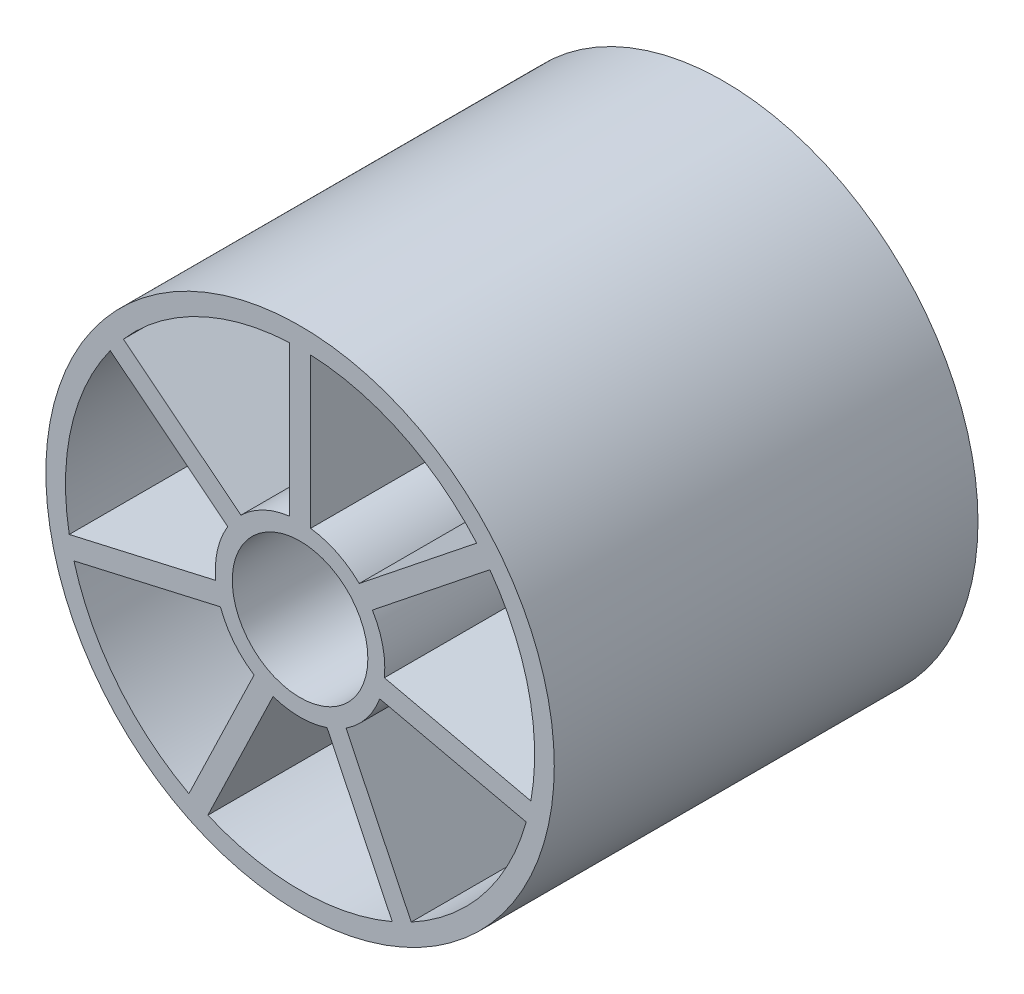
from build123d import *

# Parameters (mm, degrees)
SKETCH1_R           = 15
BOSS_EXTRUDE1_DEPTH = 25
SKETCH2_R           = 4
CUT_EXTRUDE1_DEPTH  = 25


with BuildPart() as part:
    # Sketch1 → Boss-Extrude1 (new body)
    with BuildSketch(Plane.XY):
        Circle(SKETCH1_R)
    extrude(amount=BOSS_EXTRUDE1_DEPTH)

    # Sketch2 → Cut-Extrude1 (cut)
    with BuildSketch(Plane.XY.offset(25)):
        with BuildLine():
            ThreePointArc((10.42269345, 9.106766731), (6.005266621, 12.47006463), (0.621513859, 13.826766056))
            Line((0.621513859, 13.826766056), (0.621513859, 4.961221676))
            ThreePointArc((0.621513859, 4.961221676), (2.169418696, 4.50484434), (3.491331745, 3.579190222))
            Line((3.491331745, 3.579190222), (10.42269345, 9.106766731))
        make_face()
        with BuildLine():
            Line((-0.621513859, 4.961221676), (-0.621513859, 13.826766056))
            ThreePointArc((-0.621513859, 13.826766056), (-6.005266621, 12.47006463), (-10.42269345, 9.106766731))
            Line((-10.42269345, 9.106766731), (-3.491331745, 3.579190222))
            ThreePointArc((-3.491331745, 3.579190222), (-2.169418696, 4.50484434), (-0.621513859, 4.961221676))
        make_face()
        Circle(SKETCH2_R)
        with BuildLine():
            ThreePointArc((13.618400008, -2.470813687), (13.493711611, 3.079851621), (11.197708557, 8.134928527))
            Line((11.197708557, 8.134928527), (4.266346851, 2.607352018))
            ThreePointArc((4.266346851, 2.607352018), (4.874639561, 1.11260467), (4.975133335, -0.498044472))
            Line((4.975133335, -0.498044472), (13.618400008, -2.470813687))
        make_face()
        with BuildLine():
            Line((-4.266346851, 2.607352018), (-11.197708557, 8.134928527))
            ThreePointArc((-11.197708557, 8.134928527), (-13.493711611, 3.079851621), (-13.618400008, -2.470813687))
            Line((-13.618400008, -2.470813687), (-4.975133335, -0.498044472))
            ThreePointArc((-4.975133335, -0.498044472), (-4.874639561, 1.11260467), (-4.266346851, 2.607352018))
        make_face()
        with BuildLine():
            ThreePointArc((6.559173595, -12.187821003), (10.821116537, -8.629552476), (13.341800319, -3.682676106))
            Line((13.341800319, -3.682676106), (4.698533646, -1.70990689))
            ThreePointArc((4.698533646, -1.70990689), (3.909157412, -3.117449009), (2.71255805, -4.20024152))
            Line((2.71255805, -4.20024152), (6.559173595, -12.187821003))
        make_face()
        with BuildLine():
            Line((-4.698533646, -1.70990689), (-13.341800319, -3.682676106))
            ThreePointArc((-13.341800319, -3.682676106), (-10.821116537, -8.629552476), (-6.559173595, -12.187821003))
            Line((-6.559173595, -12.187821003), (-2.71255805, -4.20024152))
            ThreePointArc((-2.71255805, -4.20024152), (-3.909157412, -3.117449009), (-4.698533646, -1.70990689))
        make_face()
        with BuildLine():
            ThreePointArc((-5.439244318, -12.727150518), (0, -13.840727548), (5.439244318, -12.727150518))
            Line((5.439244318, -12.727150518), (1.592628773, -4.739571034))
            ThreePointArc((1.592628773, -4.739571034), (0, -5), (-1.592628773, -4.739571034))
            Line((-1.592628773, -4.739571034), (-5.439244318, -12.727150518))
        make_face()
    extrude(amount=-CUT_EXTRUDE1_DEPTH, mode=Mode.SUBTRACT)


solid = part.part
